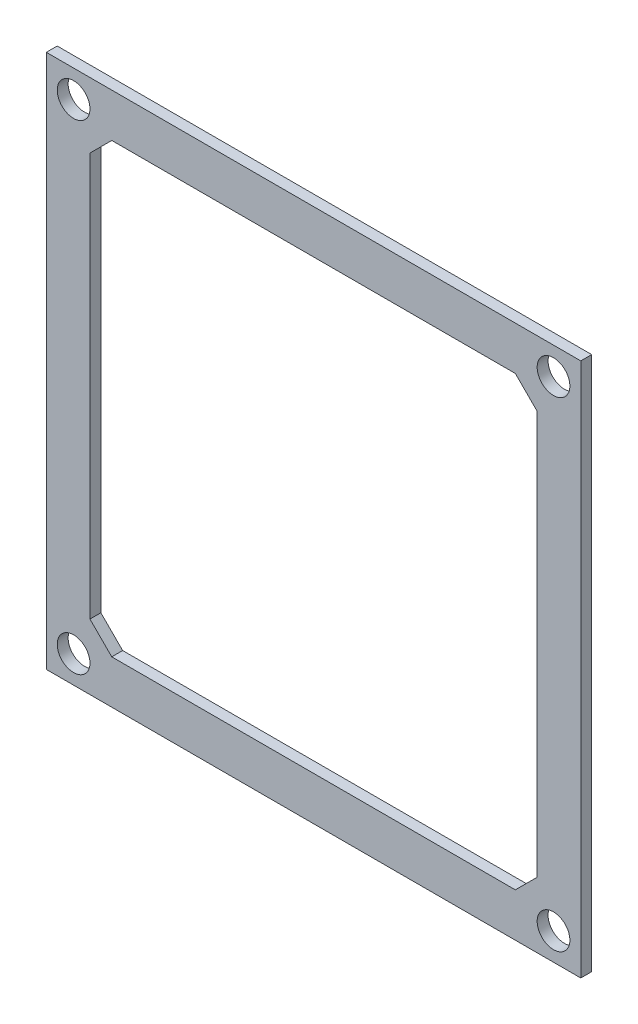
from build123d import *

# Parameters (mm, degrees)
CROQUIS1_W              = 49
CROQUIS1_H              = 49
CROQUIS1_R              = 1.5
SALIENTE_EXTRUIR1_DEPTH = 1


with BuildPart() as part:
    # Croquis1 → Saliente-Extruir1 (new body)
    with BuildSketch(Plane.XY):
        with Locations((-40.576557533, 5.197871677)):
            Rectangle(CROQUIS1_W, CROQUIS1_H)
        with Locations((-62.576557533, 27.197871677)):
            Circle(CROQUIS1_R, mode=Mode.SUBTRACT)
        with Locations((-18.576557533, 27.197871677)):
            Circle(CROQUIS1_R, mode=Mode.SUBTRACT)
        with Locations((-18.576557533, -16.802128323)):
            Circle(CROQUIS1_R, mode=Mode.SUBTRACT)
        with Locations((-62.576557533, -16.802128323)):
            Circle(CROQUIS1_R, mode=Mode.SUBTRACT)
        Polygon((-61.076557533, 23.697871677), (-61.076557533, -13.302128323), (-59.076557533, -15.302128323), (-22.076557533, -15.302128323), (-20.076557533, -13.302128323), (-20.076557533, 23.697871677), (-22.076557533, 25.697871677), (-59.076557533, 25.697871677), align=None, mode=Mode.SUBTRACT)
    extrude(amount=SALIENTE_EXTRUIR1_DEPTH)


solid = part.part
